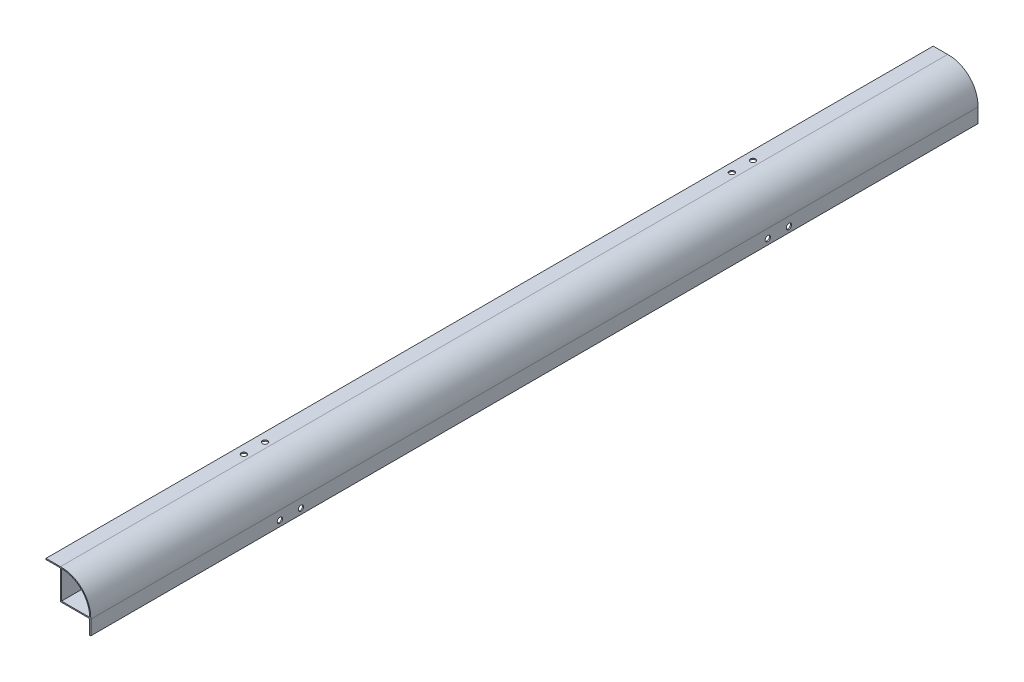
from build123d import *

# Parameters (mm, degrees)
CROQUIS1_W              = 13
CROQUIS1_H              = 1
CROQUIS1_W_2            = 1
CROQUIS1_H_2            = 13
SALIENTE_EXTRUIR1_DEPTH = 400
CROQUIS2_R              = 2.38125
CORTAR_EXTRUIR1_DEPTH   = 10
CROQUIS3_R              = 2.38125
CORTAR_EXTRUIR2_DEPTH   = 10


with BuildPart() as part:
    # Croquis1 → Saliente-Extruir1 (new body, symmetric)
    with BuildSketch(Plane.XY):
        with BuildLine():
            ThreePointArc((-13.7, 13.681053808), (5.967619023, 5.967619023), (13.681053808, -13.7))
            Line((13.681053808, -13.7), (-13.7, -13.7))
            Line((-13.7, -13.7), (-13.7, 13.681053808))
        make_face()
        with BuildLine():
            Line((-12.7, -12.7), (-12.7, 12.7))
            ThreePointArc((-12.7, 12.7), (5.260512242, 5.260512242), (12.7, -12.7))
            Line((12.7, -12.7), (-12.7, -12.7))
        make_face(mode=Mode.SUBTRACT)
        with Locations((-20.2, 13.181053808)):
            Rectangle(CROQUIS1_W, CROQUIS1_H)
        with Locations((13.181053808, -20.2)):
            Rectangle(CROQUIS1_W_2, CROQUIS1_H_2)
    extrude(amount=SALIENTE_EXTRUIR1_DEPTH, both=True)

    # Croquis2 → Cortar-Extruir1 (cut)
    with BuildSketch(Plane(origin=(0, 13.681053808, 0), x_dir=(1, 0, 0), z_dir=(0, 1, 0))):
        with Locations((-18.7, -210.5)):
            Circle(CROQUIS2_R)
        with Locations((-18.7, -229.5)):
            Circle(CROQUIS2_R)
        with Locations((-18.7, 229.5)):
            Circle(CROQUIS2_R)
        with Locations((-18.7, 210.5)):
            Circle(CROQUIS2_R)
    extrude(amount=-CORTAR_EXTRUIR1_DEPTH, mode=Mode.SUBTRACT)

    # Croquis3 → Cortar-Extruir2 (cut)
    with BuildSketch(Plane(origin=(13.681053808, 0, 0), x_dir=(0, 0, -1), z_dir=(1, 0, 0))):
        with Locations((-229.5, -21.7)):
            Circle(CROQUIS3_R)
        with Locations((-210.5, -21.7)):
            Circle(CROQUIS3_R)
        with Locations((210.5, -21.7)):
            Circle(CROQUIS3_R)
        with Locations((229.5, -21.7)):
            Circle(CROQUIS3_R)
    extrude(amount=-CORTAR_EXTRUIR2_DEPTH, mode=Mode.SUBTRACT)


solid = part.part
